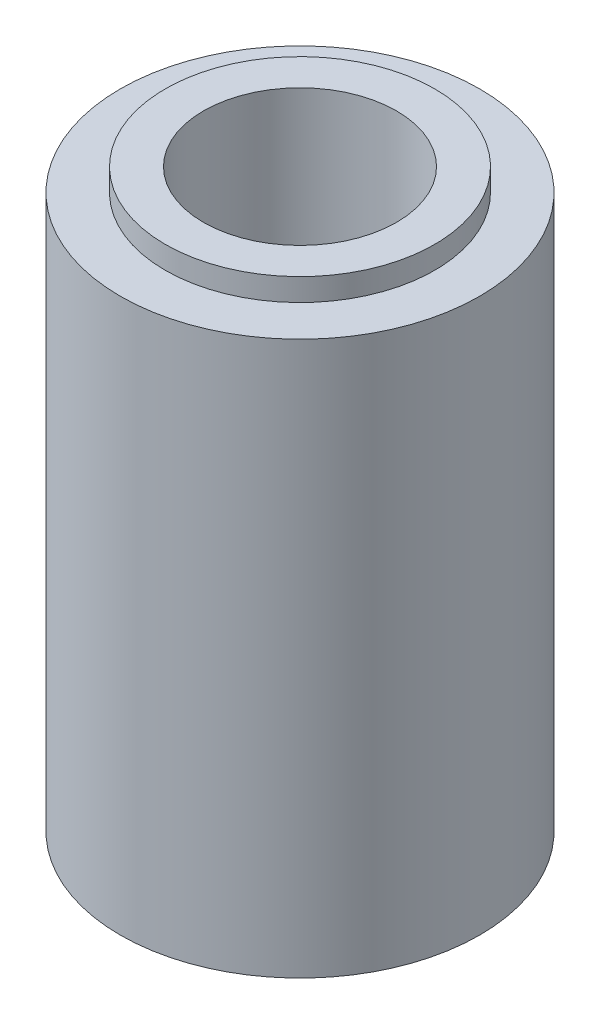
from build123d import *

# Parameters (mm, degrees)
SKETCH1_R            = 4
BOSS_EXTRUDE1_DEPTH  = 12.82
SKETCH2_OUTSIDE_W    = 13.42
SKETCH2_OUTSIDE_H    = 13.42
SKETCH2_OUTSIDE_R    = 3
CUT_EXTRUDE1_DEPTH   = 0.5
M4_CLEARANCE_HOLE1_D = 4.3


with BuildPart() as part:
    # Sketch1 → Boss-Extrude1 (new body)
    with BuildSketch(Plane(origin=(0, 0, 0), x_dir=(1, 0, 0), z_dir=(0, 1, 0))):
        Circle(SKETCH1_R)
    extrude(amount=BOSS_EXTRUDE1_DEPTH)

    # Sketch2 outside → Cut-Extrude1 (cut)
    with BuildSketch(Plane(origin=(0, 12.82, 0), x_dir=(1, 0, 0), z_dir=(0, 1, 0))):
        Rectangle(SKETCH2_OUTSIDE_W, SKETCH2_OUTSIDE_H)
        Circle(SKETCH2_OUTSIDE_R, mode=Mode.SUBTRACT)
    extrude(amount=-CUT_EXTRUDE1_DEPTH, mode=Mode.SUBTRACT)

    # M4 Clearance Hole1 (through all)
    with Locations(Plane(origin=(0, 12.82, 0), x_dir=(1, 0, 0), z_dir=(0, 1, 0))):
        with Locations((0, 0)):
            Hole(M4_CLEARANCE_HOLE1_D / 2)


solid = part.part
